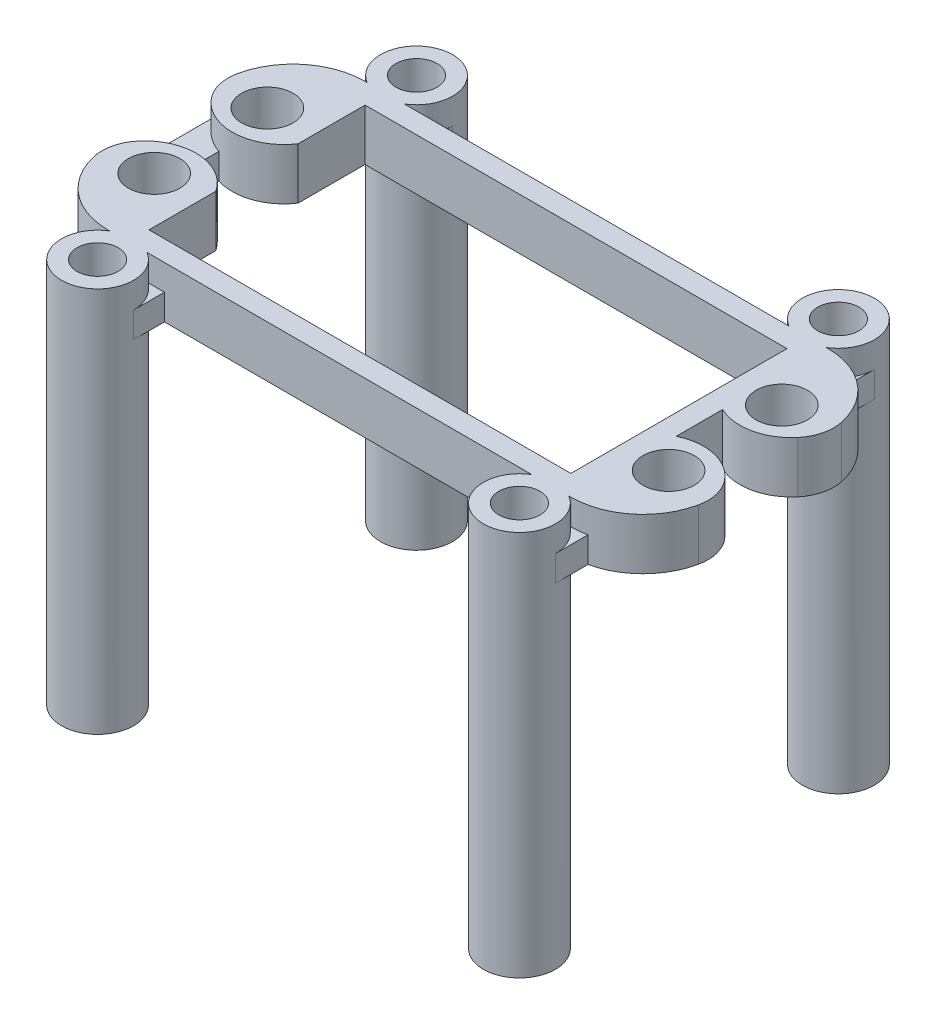
from build123d import *

# Parameters (mm, degrees)
SKETCH1_R                = 2.5
BOSS_EXTRUDE1_DEPTH      = 2.5
SKETCH4_R                = 3.5
SKETCH4_R_2              = 2
BOSS_EXTRUDE2_DEPTH      = 2.5
BOSS_EXTRUDE2_DEPTH_BACK = 35
SKETCH5_R                = 2.5
BOSS_EXTRUDE3_DEPTH      = 2.5


with BuildPart() as part:
    # Sketch1 → Boss-Extrude1 (new body)
    with BuildSketch(Plane(origin=(0, 0, 0), x_dir=(1, 0, 0), z_dir=(0, 1, 0))):
        with BuildLine():
            Line((20.5, 10.5), (-20.5, 10.5))
            Line((-20.5, 10.5), (-20.5, 4))
            ThreePointArc((-20.5, 4), (-24.40287122, 1.76806345), (-28.520566145, 3.573204173))
            ThreePointArc((-28.520566145, 3.573204173), (-29.324072849, 5.171652721), (-29.350396575, 6.960498116))
            ThreePointArc((-29.350396575, 6.960498116), (-26.904940816, 10.941842627), (-22.5, 12.5))
            Line((-22.5, 12.5), (22.5, 12.5))
            ThreePointArc((22.5, 12.5), (26.904940816, 10.941842627), (29.350396575, 6.960498116))
            ThreePointArc((29.350396575, 6.960498116), (29.324072849, 5.171652721), (28.520566145, 3.573204173))
            ThreePointArc((28.520566145, 3.573204173), (25.737402548, 1.876578025), (22.5, 2.2557411))
            Line((22.5, 2.2557411), (22.5, -2.2557411))
            ThreePointArc((22.5, -2.2557411), (25.737402548, -1.876578025), (28.520566145, -3.573204173))
            ThreePointArc((28.520566145, -3.573204173), (29.324072849, -5.171652721), (29.350396575, -6.960498116))
            ThreePointArc((29.350396575, -6.960498116), (26.904940816, -10.941842627), (22.5, -12.5))
            Line((22.5, -12.5), (-22.5, -12.5))
            ThreePointArc((-22.5, -12.5), (-26.904940816, -10.941842627), (-29.350396575, -6.960498116))
            ThreePointArc((-29.350396575, -6.960498116), (-29.324072849, -5.171652721), (-28.520566145, -3.573204173))
            ThreePointArc((-28.520566145, -3.573204173), (-24.40287122, -1.76806345), (-20.5, -4))
            Line((-20.5, -4), (-20.5, -10.5))
            Line((-20.5, -10.5), (20.5, -10.5))
            Line((20.5, -10.5), (20.5, 10.5))
        make_face()
        with Locations((-25, 5.5)):
            Circle(SKETCH1_R, mode=Mode.SUBTRACT)
        with Locations((-25, -5.5)):
            Circle(SKETCH1_R, mode=Mode.SUBTRACT)
        with Locations((25, -5.5)):
            Circle(SKETCH1_R, mode=Mode.SUBTRACT)
        with Locations((25, 5.5)):
            Circle(SKETCH1_R, mode=Mode.SUBTRACT)
    extrude(amount=BOSS_EXTRUDE1_DEPTH)

    # Sketch4 → Boss-Extrude2 (add, two sides)
    with BuildSketch(Plane(origin=(0, 0, 0), x_dir=(1, 0, 0), z_dir=(0, 1, 0))) as boss_extrude2_sk:
        with Locations((-20.5, 15.5)):
            Circle(SKETCH4_R)
        with Locations((-20.5, 15.5)):
            Circle(SKETCH4_R_2, mode=Mode.SUBTRACT)
        with Locations((20.5, 15.5)):
            Circle(SKETCH4_R)
        with Locations((20.5, 15.5)):
            Circle(SKETCH4_R_2, mode=Mode.SUBTRACT)
        with Locations((-20.5, -15.5)):
            Circle(SKETCH4_R)
        with Locations((-20.5, -15.5)):
            Circle(SKETCH4_R_2, mode=Mode.SUBTRACT)
        with Locations((20.5, -15.5)):
            Circle(SKETCH4_R)
        with Locations((20.5, -15.5)):
            Circle(SKETCH4_R_2, mode=Mode.SUBTRACT)
    extrude(amount=BOSS_EXTRUDE2_DEPTH)
    extrude(boss_extrude2_sk.sketch, amount=-BOSS_EXTRUDE2_DEPTH_BACK)

    # Sketch5 → Boss-Extrude3 (add)
    with BuildSketch(Plane(origin=(0, 0, 0), x_dir=(1, 0, 0), z_dir=(0, 1, 0))):
        with BuildLine():
            Line((-29.324072849, 5.171652721), (-29.324072849, -5.171652721))
            ThreePointArc((-29.324072849, -5.171652721), (-29.438527194, -6.064584851), (-29.350396575, -6.960498116))
            ThreePointArc((-29.350396575, -6.960498116), (-27.465923203, -10.435821373), (-24, -12.337527971))
            Line((-24, -12.337527971), (-24, -15.5))
            Line((-24, -15.5), (-22.5, -15.5))
            ThreePointArc((-22.5, -15.5), (-20.5, -13.5), (-18.5, -15.5))
            Line((-18.5, -15.5), (-17, -15.5))
            Line((-17, -15.5), (-17, -12.5))
            Line((-17, -12.5), (17, -12.5))
            Line((17, -12.5), (17, -15.5))
            Line((17, -15.5), (18.5, -15.5))
            ThreePointArc((18.5, -15.5), (20.5, -13.5), (22.5, -15.5))
            Line((22.5, -15.5), (24, -15.5))
            Line((24, -15.5), (24, -12.337527971))
            ThreePointArc((24, -12.337527971), (27.465923203, -10.435821373), (29.350396575, -6.960498116))
            ThreePointArc((29.350396575, -6.960498116), (29.324072849, -5.171652721), (28.520566145, -3.573204173))
            ThreePointArc((28.520566145, -3.573204173), (25.737402548, -1.876578025), (22.5, -2.2557411))
            Line((22.5, -2.2557411), (22.5, 2.2557411))
            ThreePointArc((22.5, 2.2557411), (25.737402548, 1.876578025), (28.520566145, 3.573204173))
            ThreePointArc((28.520566145, 3.573204173), (29.324072849, 5.171652721), (29.350396575, 6.960498116))
            ThreePointArc((29.350396575, 6.960498116), (27.465923203, 10.435821373), (24, 12.337527971))
            Line((24, 12.337527971), (24, 15.5))
            Line((24, 15.5), (22.5, 15.5))
            ThreePointArc((22.5, 15.5), (20.5, 13.5), (18.5, 15.5))
            Line((18.5, 15.5), (17, 15.5))
            Line((17, 15.5), (17, 12.5))
            Line((17, 12.5), (-17, 12.5))
            Line((-17, 12.5), (-17, 15.5))
            Line((-17, 15.5), (-18.5, 15.5))
            ThreePointArc((-18.5, 15.5), (-20.5, 13.5), (-22.5, 15.5))
            Line((-22.5, 15.5), (-24, 15.5))
            Line((-24, 15.5), (-24, 12.337527971))
            ThreePointArc((-24, 12.337527971), (-27.465923203, 10.435821373), (-29.350396575, 6.960498116))
            ThreePointArc((-29.350396575, 6.960498116), (-29.438527194, 6.064584851), (-29.324072849, 5.171652721))
        make_face()
        with Locations((-25, 5.5)):
            Circle(SKETCH5_R, mode=Mode.SUBTRACT)
        with Locations((-25, -5.5)):
            Circle(SKETCH5_R, mode=Mode.SUBTRACT)
        with Locations((25, -5.5)):
            Circle(SKETCH5_R, mode=Mode.SUBTRACT)
        with Locations((25, 5.5)):
            Circle(SKETCH5_R, mode=Mode.SUBTRACT)
        with BuildLine():
            Line((-26.208643878, 2.004095257), (-26.208643878, -2.004095257))
            ThreePointArc((-26.208643878, -2.004095257), (-23.018368657, -2.041161266), (-20.5, -4))
            Line((-20.5, -4), (-20.5, -10.5))
            Line((-20.5, -10.5), (20.5, -10.5))
            Line((20.5, -10.5), (20.5, 10.5))
            Line((20.5, 10.5), (-20.5, 10.5))
            Line((-20.5, 10.5), (-20.5, 4))
            ThreePointArc((-20.5, 4), (-23.018368657, 2.041161266), (-26.208643878, 2.004095257))
        make_face(mode=Mode.SUBTRACT)
    extrude(amount=-BOSS_EXTRUDE3_DEPTH)


solid = part.part
